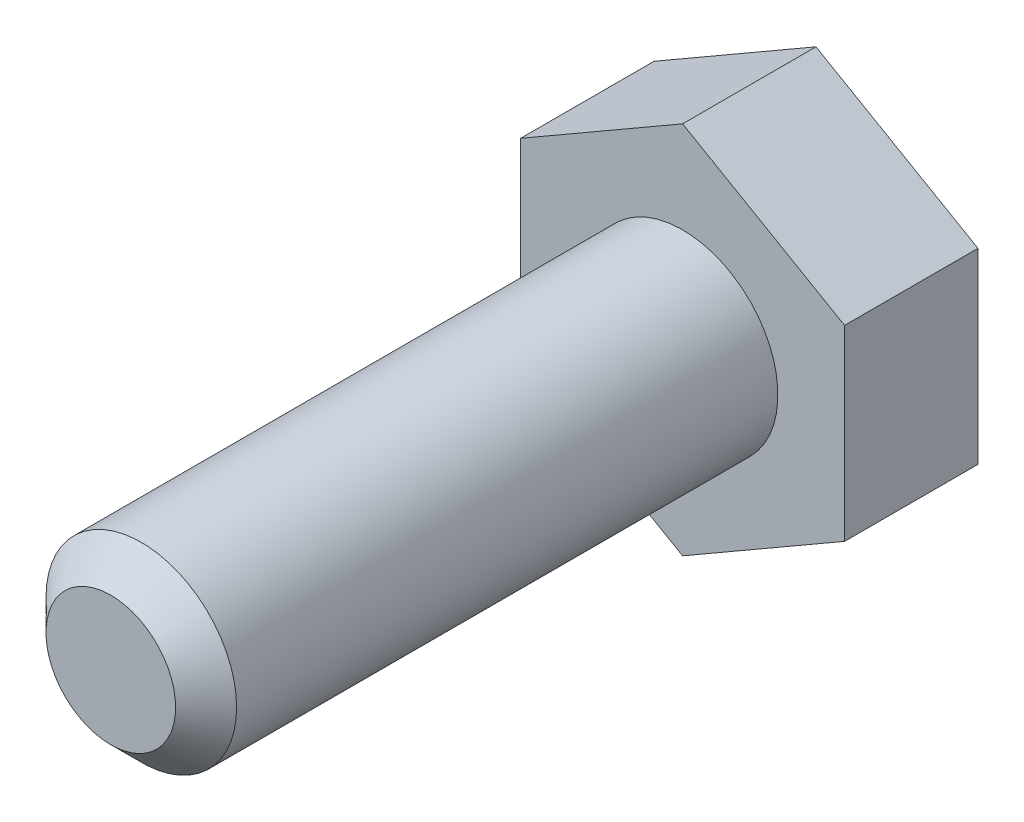
from build123d import *

# Parameters (mm, degrees)
SKETCH1_R           = 5
BASE_EXTRUDE_DEPTH  = 30
BOSS_EXTRUDE2_DEPTH = 7
CHAMFER1_SIZE       = 1.6


with BuildPart() as part:
    # Sketch1 → Base-Extrude (new body)
    with BuildSketch(Plane.XY):
        Circle(SKETCH1_R)
    extrude(amount=BASE_EXTRUDE_DEPTH)

    # Sketch2 → Boss-Extrude2 (add)
    with BuildSketch(Plane(origin=(0, 0, 0), x_dir=(-1, 0, 0), z_dir=(0, 0, -1))):
        Polygon((0, 9.814954576), (-8.5, 4.907477288), (-8.5, -4.907477288), (0, -9.814954576), (8.5, -4.907477288), (8.5, 4.907477288), align=None)
    extrude(amount=BOSS_EXTRUDE2_DEPTH)

    # Chamfer1
    chamfer1_edges = [part.edges().sort_by_distance(p)[0] for p in [
        (-5, 0, 30),
    ]]
    chamfer(chamfer1_edges, length=CHAMFER1_SIZE)


solid = part.part
